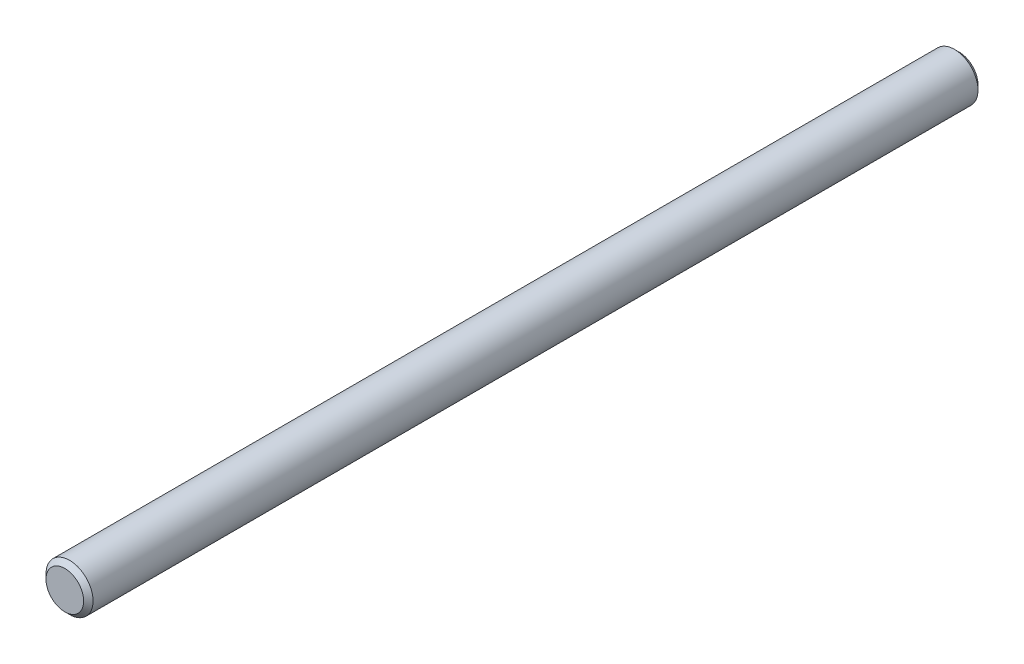
from build123d import *

# Parameters (mm, degrees)
SKETCH1_R           = 3.175
BOSS_EXTRUDE1_DEPTH = 60.325
CHAMFER1_SIZE       = 0.635


with BuildPart() as part:
    # Sketch1 → Boss-Extrude1 (new body, symmetric)
    with BuildSketch(Plane.XY):
        Circle(SKETCH1_R)
    extrude(amount=BOSS_EXTRUDE1_DEPTH, both=True)

    # Chamfer1
    chamfer1_edges = [part.edges().sort_by_distance(p)[0] for p in [
        (-3.175, 0, -60.325),
        (-3.175, 0, 60.325),
    ]]
    chamfer(chamfer1_edges, length=CHAMFER1_SIZE)


solid = part.part
